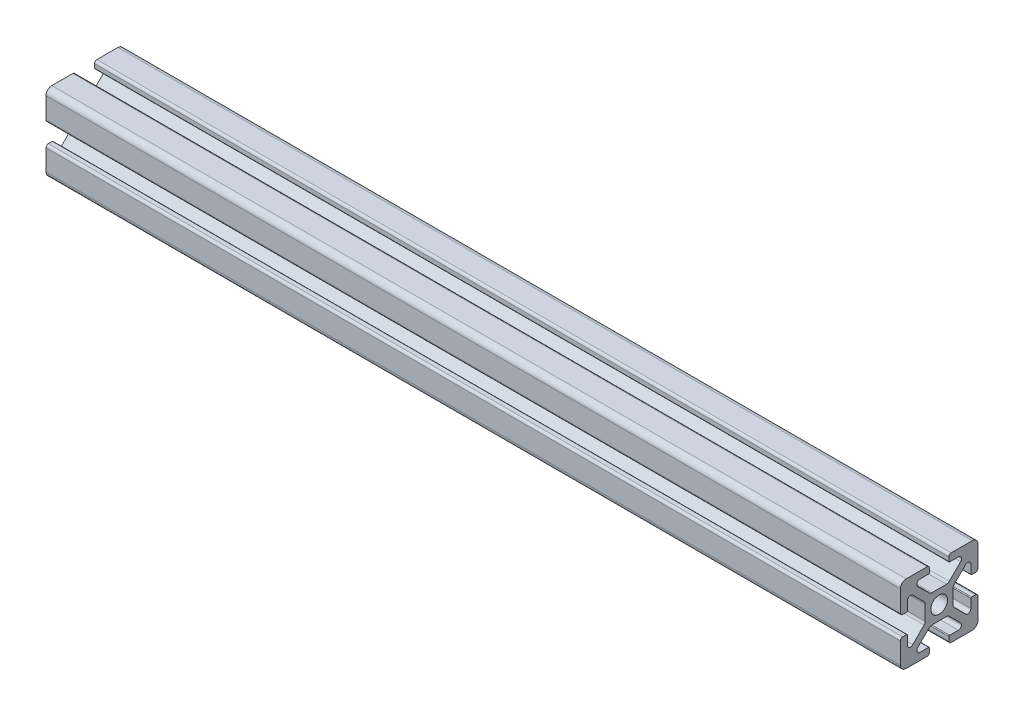
from build123d import *

# Parameters (mm, degrees)
BOSS_EXTRUDE1_DEPTH = 220


with BuildPart() as part:
    # Sketch3 → Boss-Extrude1 (new body)
    with BuildSketch(Plane(origin=(0, 0, 0), x_dir=(0, 0, -1), z_dir=(1, 0, 0))):
        with BuildLine():
            Line((-5.515685425, 6.807463915), (-2.601114729, 3.892893219))
            ThreePointArc((-2.601114729, 3.892893219), (-2.27669138, 3.676120467), (-1.894007948, 3.6))
            Line((-1.894007948, 3.6), (0, 3.6))
            Line((0, 3.6), (0, 2.15))
            ThreePointArc((0, 2.15), (-1.52027958, 1.52027958), (-2.15, 0))
            Line((-2.15, 0), (-3.6, 0))
            Line((-3.6, 0), (-3.6, 1.894007948))
            ThreePointArc((-3.6, 1.894007948), (-3.676120467, 2.27669138), (-3.892893219, 2.601114729))
            Line((-3.892893219, 2.601114729), (-6.807463915, 5.515685425))
            ThreePointArc((-6.807463915, 5.515685425), (-7.679296086, 5.689103626), (-8.17314934, 4.95))
            Line((-8.17314934, 4.95), (-8.17314934, 2.7))
            ThreePointArc((-8.17314934, 2.7), (-8.231727984, 2.558578644), (-8.37314934, 2.5))
            Line((-8.37314934, 2.5), (-9.4, 2.5))
            ThreePointArc((-9.4, 2.5), (-9.824264069, 2.675735931), (-10, 3.1))
            Line((-10, 3.1), (-10, 8.5))
            ThreePointArc((-10, 8.5), (-9.560660172, 9.560660172), (-8.5, 10))
            Line((-8.5, 10), (-3.1, 10))
            ThreePointArc((-3.1, 10), (-2.675735931, 9.824264069), (-2.5, 9.4))
            Line((-2.5, 9.4), (-2.5, 8.37314934))
            ThreePointArc((-2.5, 8.37314934), (-2.558578644, 8.231727984), (-2.7, 8.17314934))
            Line((-2.7, 8.17314934), (-4.95, 8.17314934))
            ThreePointArc((-4.95, 8.17314934), (-5.689103626, 7.679296086), (-5.515685425, 6.807463915))
        make_face()
    extrude(amount=-BOSS_EXTRUDE1_DEPTH)

    # Mirror1: part across plane


with BuildPart() as part_1:
    add(part.part)
    add(part.part.mirror(Plane.ZX))

    # Mirror2: part across plane


with BuildPart() as part_2:
    add(part_1.part)
    add(part_1.part.mirror(Plane.XY))


solid = part_2.part
